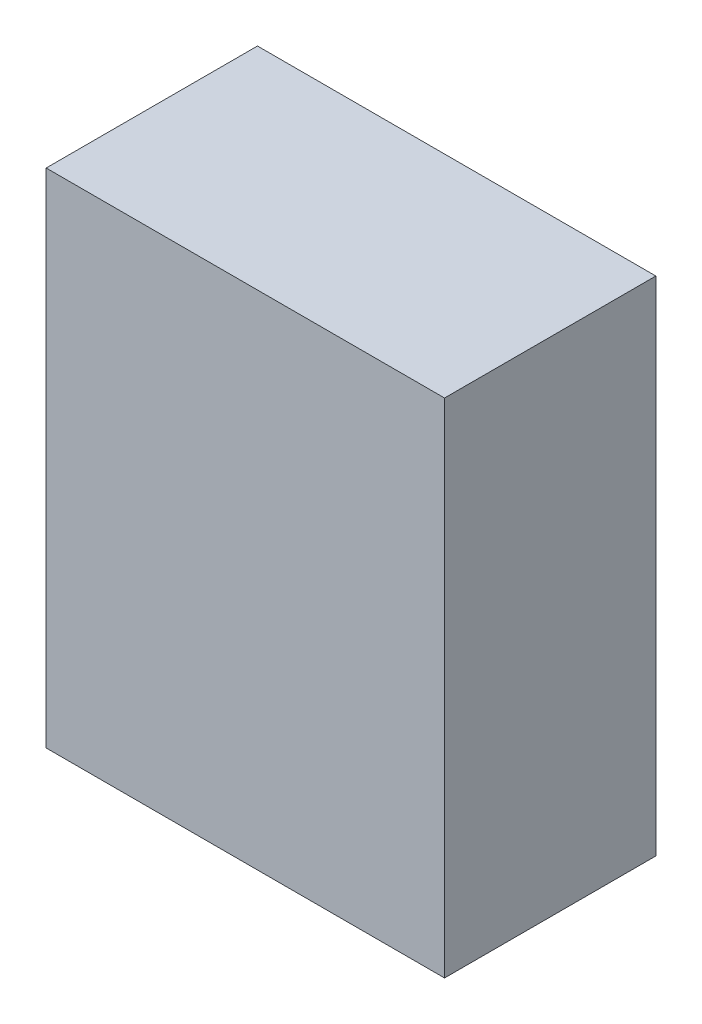
from build123d import *

# Parameters (mm, degrees)
SKETCH1_W           = 23
SKETCH1_H           = 12.2
BOSS_EXTRUDE1_DEPTH = 29


with BuildPart() as part:
    # Sketch1 → Boss-Extrude1 (new body)
    with BuildSketch(Plane(origin=(0, 0, 0), x_dir=(1, 0, 0), z_dir=(0, 1, 0))):
        with Locations((2.772321429, 0.317410714)):
            Rectangle(SKETCH1_W, SKETCH1_H)
    extrude(amount=BOSS_EXTRUDE1_DEPTH)


solid = part.part
